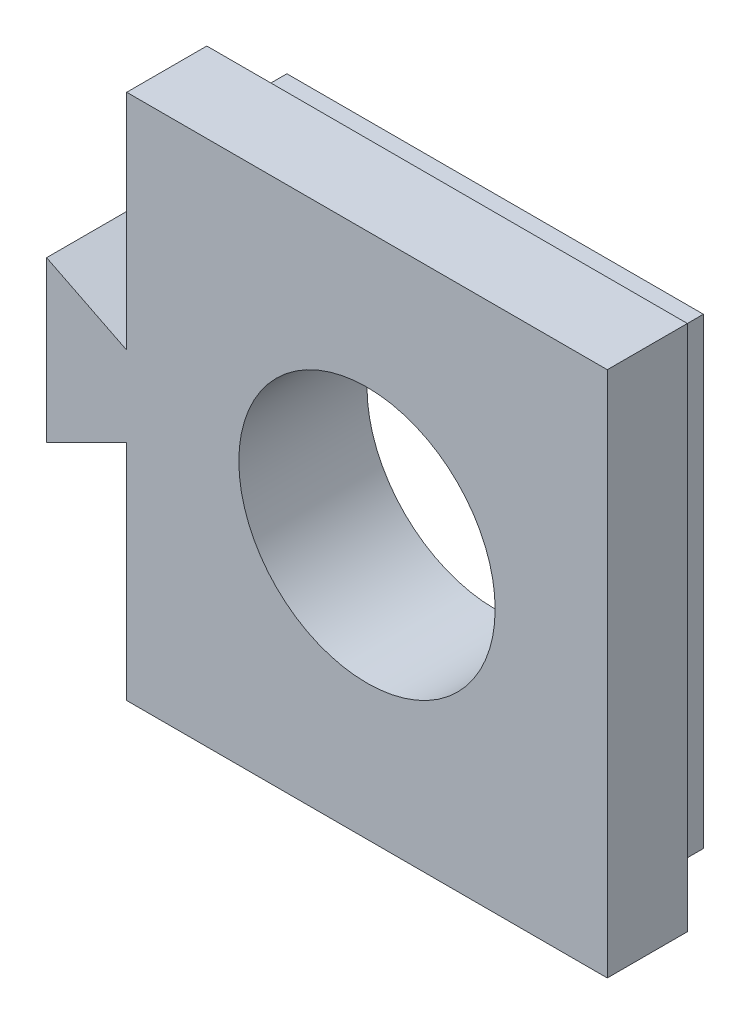
from build123d import *

# Parameters (mm, degrees)
CROQUIS1_W              = 26
CROQUIS1_H              = 28.884781413
CROQUIS1_R              = 8
SALIENTE_EXTRUIR1_DEPTH = 3
CROQUIS2_W              = 30
CROQUIS2_H              = 32.884781413
SALIENTE_EXTRUIR2_DEPTH = 5
SALIENTE_EXTRUIR3_DEPTH = 5
CROQUIS5_R              = 8
CORTAR_EXTRUIR1_DEPTH   = 10


with BuildPart() as part:
    # Croquis1 → Saliente-Extruir1 (new body)
    with BuildSketch(Plane.XY):
        with Locations((11, 9.157609294)):
            Rectangle(CROQUIS1_W, CROQUIS1_H)
        with Locations((11, 9.157609293)):
            Circle(CROQUIS1_R, mode=Mode.SUBTRACT)
    extrude(amount=SALIENTE_EXTRUIR1_DEPTH)

    # Croquis2 → Saliente-Extruir2 (add)
    with BuildSketch(Plane.XY.offset(3)):
        with Locations((11, 9.157609294)):
            Rectangle(CROQUIS2_W, CROQUIS2_H)
    extrude(amount=SALIENTE_EXTRUIR2_DEPTH)

    # Croquis4 → Saliente-Extruir3 (add)
    with BuildSketch(Plane.XY.offset(8)):
        Polygon((-9, 14.157609293), (-9, 4.157609293), (-4, 6.657609293), (-4, 11.657609293), align=None)
    extrude(amount=-SALIENTE_EXTRUIR3_DEPTH)

    # Croquis5 → Cortar-Extruir1 (cut)
    with BuildSketch(Plane(origin=(0, 0, 3), x_dir=(-1, 0, 0), z_dir=(0, 0, -1))):
        with Locations((-11, 9.157609293)):
            Circle(CROQUIS5_R)
    extrude(amount=-CORTAR_EXTRUIR1_DEPTH, mode=Mode.SUBTRACT)


solid = part.part
